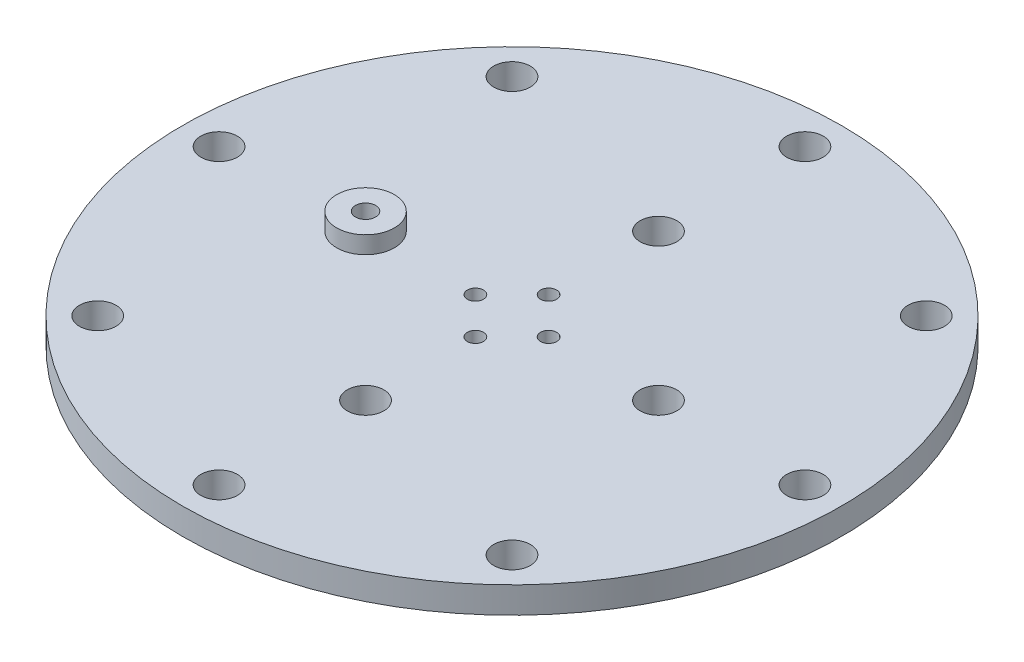
from build123d import *

# Parameters (mm, degrees)
SKETCH1_R           = 57.15
SKETCH1_R_2         = 1.397
SKETCH1_R_3         = 3.175
BOSS_EXTRUDE1_DEPTH = 4.572
SKETCH2_R           = 2.75
SKETCH2_R_2         = 1.75
BOSS_EXTRUDE2_DEPTH = 2
SKETCH3_R           = 5
SKETCH3_R_2         = 1.75
BOSS_EXTRUDE3_DEPTH = 3


with BuildPart() as part:
    # Sketch1 → Boss-Extrude1 (new body)
    with BuildSketch(Plane(origin=(0, 0, 0), x_dir=(1, 0, 0), z_dir=(0, 1, 0))):
        Circle(SKETCH1_R)
        with Locations((0, 6.35)):
            Circle(SKETCH1_R_2, mode=Mode.SUBTRACT)
        with Locations((0, 25.4)):
            Circle(SKETCH1_R_3, mode=Mode.SUBTRACT)
        with Locations((0, 50.8)):
            Circle(SKETCH1_R_3, mode=Mode.SUBTRACT)
        with Locations((25.4, 0)):
            Circle(SKETCH1_R_3, mode=Mode.SUBTRACT)
        with Locations((0, -25.4)):
            Circle(SKETCH1_R_3, mode=Mode.SUBTRACT)
        with Locations((-25.4, 0)):
            Circle(SKETCH1_R_3, mode=Mode.SUBTRACT)
        with Locations((6.35, 0)):
            Circle(SKETCH1_R_2, mode=Mode.SUBTRACT)
        with Locations((0, -6.35)):
            Circle(SKETCH1_R_2, mode=Mode.SUBTRACT)
        with Locations((-6.35, 0)):
            Circle(SKETCH1_R_2, mode=Mode.SUBTRACT)
        with Locations((35.921024484, 35.921024484)):
            Circle(SKETCH1_R_3, mode=Mode.SUBTRACT)
        with Locations((50.8, 0)):
            Circle(SKETCH1_R_3, mode=Mode.SUBTRACT)
        with Locations((35.921024484, -35.921024484)):
            Circle(SKETCH1_R_3, mode=Mode.SUBTRACT)
        with Locations((0, -50.8)):
            Circle(SKETCH1_R_3, mode=Mode.SUBTRACT)
        with Locations((-35.921024484, -35.921024484)):
            Circle(SKETCH1_R_3, mode=Mode.SUBTRACT)
        with Locations((-50.8, 0)):
            Circle(SKETCH1_R_3, mode=Mode.SUBTRACT)
        with Locations((-35.921024484, 35.921024484)):
            Circle(SKETCH1_R_3, mode=Mode.SUBTRACT)
    extrude(amount=BOSS_EXTRUDE1_DEPTH)


with BuildPart() as body_2:
    # Sketch2 → Boss-Extrude2 (new body)
    with BuildSketch(Plane(origin=(0, 4.572, 0), x_dir=(1, 0, 0), z_dir=(0, 1, 0))):
        with Locations((-25.4, 0)):
            Circle(SKETCH2_R)
        with Locations((-25.4, 0)):
            Circle(SKETCH2_R_2, mode=Mode.SUBTRACT)
    extrude(amount=-BOSS_EXTRUDE2_DEPTH)

    # Sketch3 → Boss-Extrude3 (add)
    with BuildSketch(Plane(origin=(0, 4.572, 0), x_dir=(1, 0, 0), z_dir=(0, 1, 0))):
        with Locations((-25.4, 0)):
            Circle(SKETCH3_R)
        with Locations((-25.4, 0)):
            Circle(SKETCH3_R_2, mode=Mode.SUBTRACT)
    extrude(amount=BOSS_EXTRUDE3_DEPTH)


solid = Compound([part.part, body_2.part])
